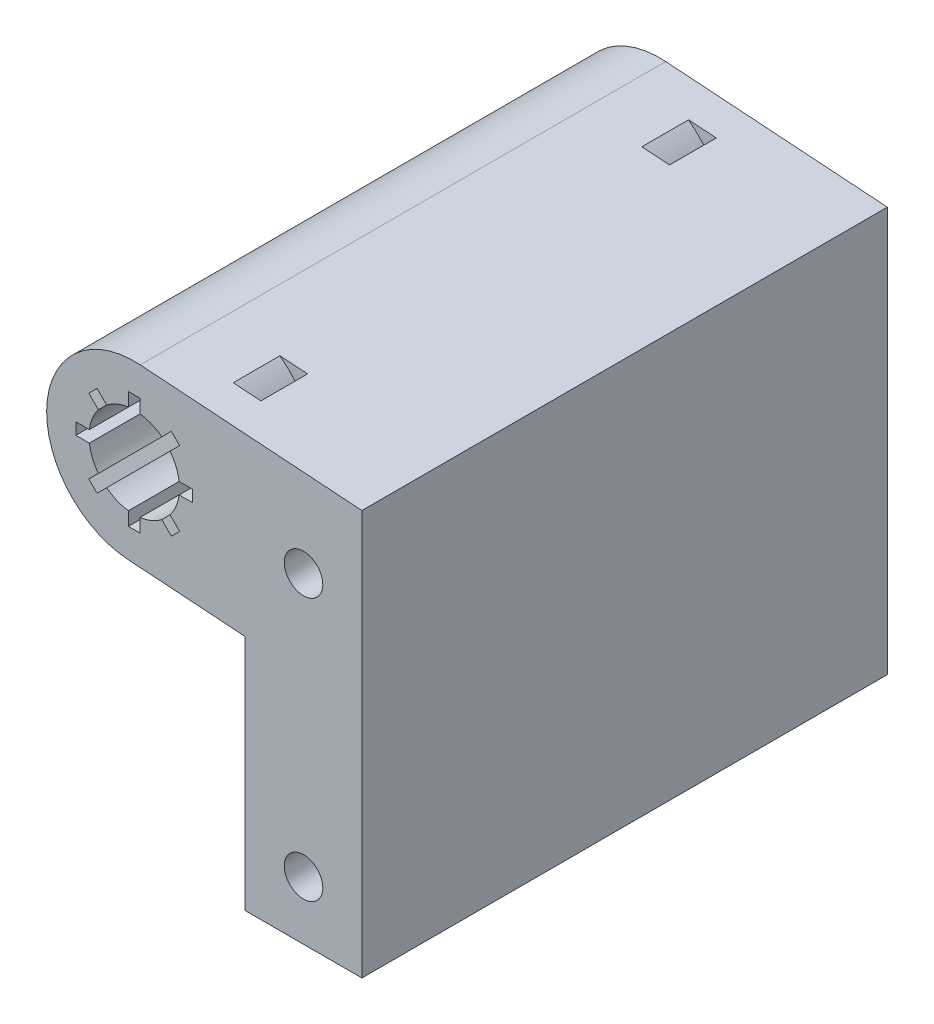
from build123d import *

# Parameters (mm, degrees)
BOSS_EXTRUDE1_DEPTH   = 45
CUT_EXTRUDE1_START    = -5
CUT_EXTRUDE1_DEPTH    = 2
M4X0_7_TAPPED_HOLE1_D = 3.3
SKETCH5_R             = 7.5
BOSS_EXTRUDE2_DEPTH   = 45
SKETCH6_R             = 3.875
CUT_EXTRUDE2_DEPTH    = 46
CUT_EXTRUDE4_DEPTH    = 46


with BuildPart() as part:
    # Sketch1 → Boss-Extrude1 (new body)
    with BuildSketch(Plane.XY):
        with BuildLine():
            Line((-182.516015687, 162.517772537), (-172.5, 161.827012834))
            Line((-172.5, 161.827012834), (-172.5, 141.5))
            Line((-172.5, 141.5), (-162.5, 141.5))
            Line((-162.5, 141.5), (-162.5, 176.172987166))
            Line((-162.5, 176.172987166), (-181.483984313, 177.482227463))
            ThreePointArc((-181.483984313, 177.482227463), (-174.517772537, 169.483984313), (-182.516015687, 162.517772537))
        make_face()
    extrude(amount=BOSS_EXTRUDE1_DEPTH)

    # Sketch2 → Cut-Extrude1 (cut, symmetric)
    with BuildSketch(Plane(origin=(0, 0, 0), x_dir=(-1, 0, 0), z_dir=(0, 0, -1)).offset(CUT_EXTRUDE1_START)):
        with BuildLine():
            ThreePointArc((176.520836095, 177.139941379), (173.021327044, 169.380781175), (177.552867469, 162.175486453))
            ThreePointArc((177.552867469, 162.175486453), (177.834315887, 161.15284928), (176.811678714, 160.871400862))
            ThreePointArc((176.811678714, 160.871400862), (171.524881552, 169.277578038), (175.60764211, 178.329931609))
            ThreePointArc((175.60764211, 178.329931609), (176.659234217, 178.191533486), (176.520836095, 177.139941379))
        make_face()
    cut_extrude1 = extrude(amount=CUT_EXTRUDE1_DEPTH, both=True, mode=Mode.SUBTRACT)

    # Mirror1: Cut-Extrude1 across plane
    add(cut_extrude1.mirror(Plane(origin=(0, 0, 22.5), x_dir=(1, 0, 0), z_dir=(0, 0, -1))), mode=Mode.SUBTRACT)

    # M4x0.7 Tapped Hole1 (through all)
    with Locations(Plane.XY.offset(45)):
        with Locations((-167.5, 169), (-167.5, 146.5)):
            Hole(M4X0_7_TAPPED_HOLE1_D / 2)

    # Sketch5 → Boss-Extrude2 (add, through all)
    with BuildSketch(Plane.XY.offset(45)):
        with Locations((-182, 170)):
            Circle(SKETCH5_R)
    extrude(amount=-BOSS_EXTRUDE2_DEPTH)

    # Sketch6 → Cut-Extrude2 (cut, through all)
    with BuildSketch(Plane.XY.offset(45)):
        with Locations((-182, 170)):
            Circle(SKETCH6_R)
    extrude(amount=-CUT_EXTRUDE2_DEPTH, mode=Mode.SUBTRACT)

    # Sketch8 → Cut-Extrude4 (cut, through all)
    with BuildSketch(Plane.XY.offset(45)):
        with BuildLine():
            ThreePointArc((-178.929313469, 167.636420251), (-179.259961223, 167.259961223), (-179.636420251, 166.929313469))
            Line((-179.636420251, 166.929313469), (-178.818019485, 166.110912703))
            Line((-178.818019485, 166.110912703), (-178.110912703, 166.818019485))
            Line((-178.110912703, 166.818019485), (-178.929313469, 167.636420251))
        make_face()
        with BuildLine():
            Line((-182.5, 166.157393463), (-182.5, 165))
            Line((-182.5, 165), (-181.5, 165))
            Line((-181.5, 165), (-181.5, 166.157393463))
            ThreePointArc((-181.5, 166.157393463), (-182, 166.125), (-182.5, 166.157393463))
        make_face()
        with BuildLine():
            Line((-185.181980515, 166.110912703), (-184.363579749, 166.929313469))
            ThreePointArc((-184.363579749, 166.929313469), (-184.740038777, 167.259961223), (-185.070686531, 167.636420251))
            Line((-185.070686531, 167.636420251), (-185.889087297, 166.818019485))
            Line((-185.889087297, 166.818019485), (-185.181980515, 166.110912703))
        make_face()
        with BuildLine():
            Line((-187, 169.5), (-185.842606537, 169.5))
            ThreePointArc((-185.842606537, 169.5), (-185.875, 170), (-185.842606537, 170.5))
            Line((-185.842606537, 170.5), (-187, 170.5))
            Line((-187, 170.5), (-187, 169.5))
        make_face()
        with BuildLine():
            Line((-185.889087297, 173.181980515), (-185.070686531, 172.363579749))
            ThreePointArc((-185.070686531, 172.363579749), (-184.740038777, 172.740038777), (-184.363579749, 173.070686531))
            Line((-184.363579749, 173.070686531), (-185.181980515, 173.889087297))
            Line((-185.181980515, 173.889087297), (-185.889087297, 173.181980515))
        make_face()
        with BuildLine():
            Line((-182.5, 175), (-182.5, 173.842606537))
            ThreePointArc((-182.5, 173.842606537), (-182, 173.875), (-181.5, 173.842606537))
            Line((-181.5, 173.842606537), (-181.5, 175))
            Line((-181.5, 175), (-182.5, 175))
        make_face()
        with BuildLine():
            ThreePointArc((-179.636420251, 173.070686531), (-179.259961223, 172.740038777), (-178.929313469, 172.363579749))
            Line((-178.929313469, 172.363579749), (-178.110912703, 173.181980515))
            Line((-178.110912703, 173.181980515), (-178.818019485, 173.889087297))
            Line((-178.818019485, 173.889087297), (-179.636420251, 173.070686531))
        make_face()
        with BuildLine():
            ThreePointArc((-178.125, 170), (-178.133106846, 169.749475881), (-178.157393463, 169.5))
            Line((-178.157393463, 169.5), (-177, 169.5))
            Line((-177, 169.5), (-177, 170.5))
            Line((-177, 170.5), (-178.157393463, 170.5))
            ThreePointArc((-178.157393463, 170.5), (-178.133106846, 170.250524119), (-178.125, 170))
        make_face()
    extrude(amount=-CUT_EXTRUDE4_DEPTH, mode=Mode.SUBTRACT)


solid = part.part
